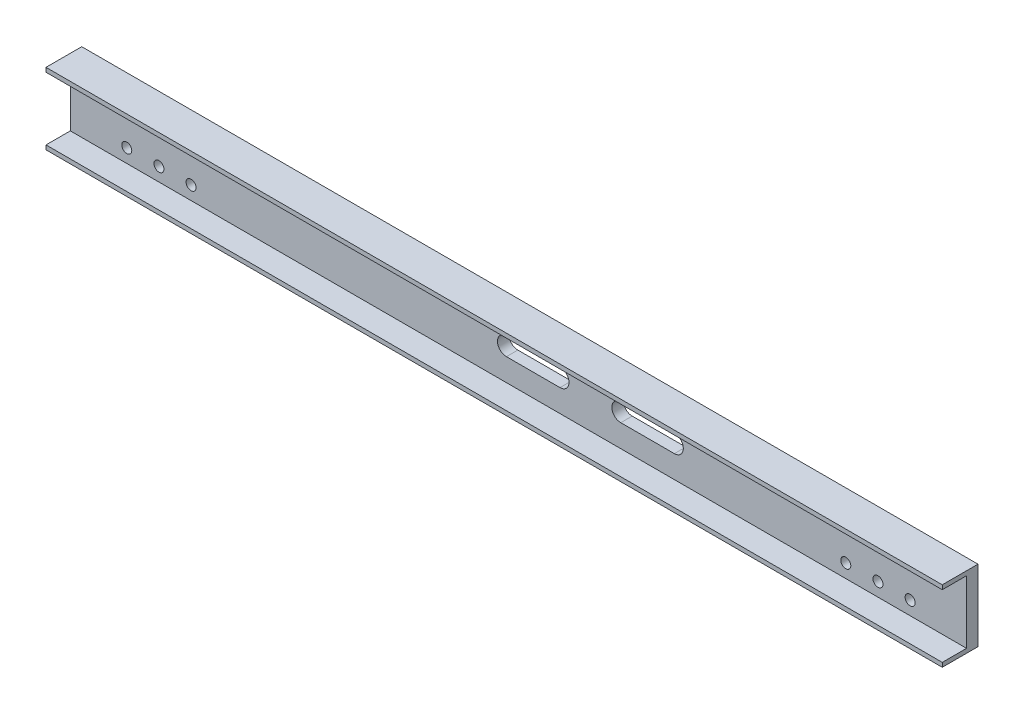
from build123d import *

# Parameters (mm, degrees)
SKETCH1_W               = 34
SKETCH1_H               = 6
SKETCH1_W_2             = 16
SKETCH1_H_2             = 88
BOSS_EXTRUDE1_DEPTH     = 1254
F_12_0MM_DOWEL_HOLE1_D  = 14
CUT_EXTRUDE1_DEPTH      = 35
CUT_EXTRUDE1_DEPTH_BACK = 17


with BuildPart() as part:
    # Sketch1 → Boss-Extrude1 (new body)
    with BuildSketch(Plane(origin=(0, 0, 0), x_dir=(0, 0, -1), z_dir=(1, 0, 0))):
        with Locations((-25, 47)):
            Rectangle(SKETCH1_W, SKETCH1_H)
        with Locations((0, 47)):
            Rectangle(SKETCH1_W_2, SKETCH1_H)
        Rectangle(SKETCH1_W_2, SKETCH1_H_2)
        with Locations((0, -47)):
            Rectangle(SKETCH1_W_2, SKETCH1_H)
        with Locations((-25, -47)):
            Rectangle(SKETCH1_W, SKETCH1_H)
    extrude(amount=BOSS_EXTRUDE1_DEPTH)

    # Ø12.0mm Dowel Hole1 (through all)
    with Locations(Plane.XY.offset(8)):
        with Locations((1175, 25), (1130, 25), (1085, 25), (1085, -25), (1130, -25), (1175, -25), (79, 25), (124, 25), (169, 25), (169, -25), (124, -25), (79, -25)):
            Hole(F_12_0MM_DOWEL_HOLE1_D / 2)

    # Sketch7 → Cut-Extrude1 (cut, two sides)
    with BuildSketch(Plane.XY.offset(8)) as cut_extrude1_sk:
        with BuildLine():
            Line((770.18, 12.5), (845.18, 12.5))
            ThreePointArc((845.18, 12.5), (857.68, 0), (845.18, -12.5))
            Line((845.18, -12.5), (770.18, -12.5))
            ThreePointArc((770.18, -12.5), (757.68, 0), (770.18, 12.5))
        make_face()
        with BuildLine():
            Line((685.18, -12.5), (610.18, -12.5))
            ThreePointArc((610.18, -12.5), (597.68, 0), (610.18, 12.5))
            Line((610.18, 12.5), (685.18, 12.5))
            ThreePointArc((685.18, 12.5), (697.68, 0), (685.18, -12.5))
        make_face()
    extrude(amount=CUT_EXTRUDE1_DEPTH, mode=Mode.SUBTRACT)
    extrude(cut_extrude1_sk.sketch, amount=-CUT_EXTRUDE1_DEPTH_BACK, mode=Mode.SUBTRACT)


solid = part.part
